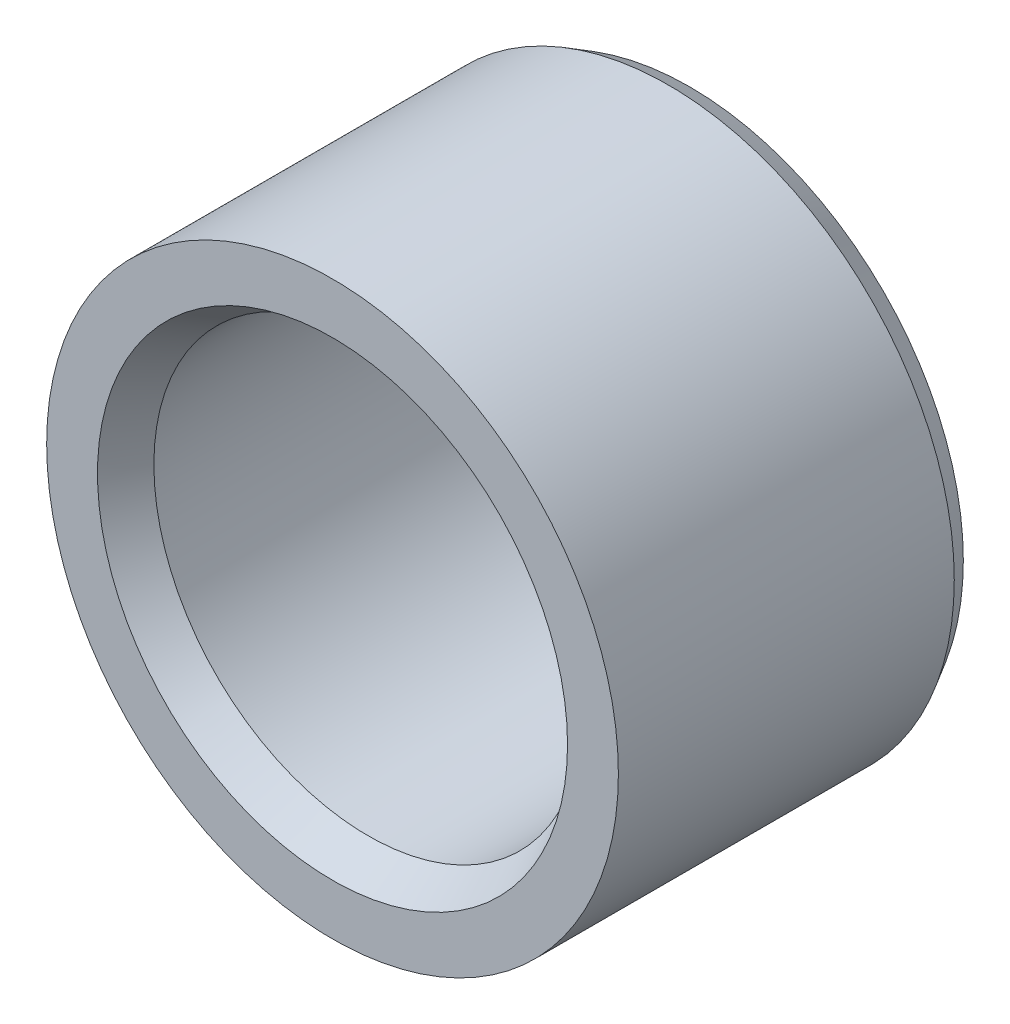
from build123d import *

# Parameters (mm, degrees)
SKETCH1_R           = 4
SKETCH1_R_2         = 3
BOSS_EXTRUDE1_DEPTH = 5
CHAMFER1_SIZE       = 0.3
CHAMFER1_SIZE2      = 0.173205081
CHAMFER2_SIZE       = 0.5
CHAMFER2_SIZE2      = 0.288675135


with BuildPart() as part:
    # Sketch1 → Boss-Extrude1 (new body)
    with BuildSketch(Plane.XY):
        Circle(SKETCH1_R)
        Circle(SKETCH1_R_2, mode=Mode.SUBTRACT)
    extrude(amount=BOSS_EXTRUDE1_DEPTH)

    # Chamfer1
    chamfer1_edges = [part.edges().sort_by_distance(p)[0] for p in [
        (-4, 0, 0),
    ]]
    chamfer1_side = [part.faces().sort_by_distance(p)[0] for p in [
        (-4, 0, 2.5),
    ]]
    chamfer(chamfer1_edges, length=CHAMFER1_SIZE, length2=CHAMFER1_SIZE2, reference=chamfer1_side[0])

    # Chamfer2
    chamfer2_edges = [part.edges().sort_by_distance(p)[0] for p in [
        (-3, 0, 5),
    ]]
    chamfer2_side = [part.faces().sort_by_distance(p)[0] for p in [
        (-3, 0, 2.5),
    ]]
    chamfer(chamfer2_edges, length=CHAMFER2_SIZE, length2=CHAMFER2_SIZE2, reference=chamfer2_side[0])


solid = part.part
